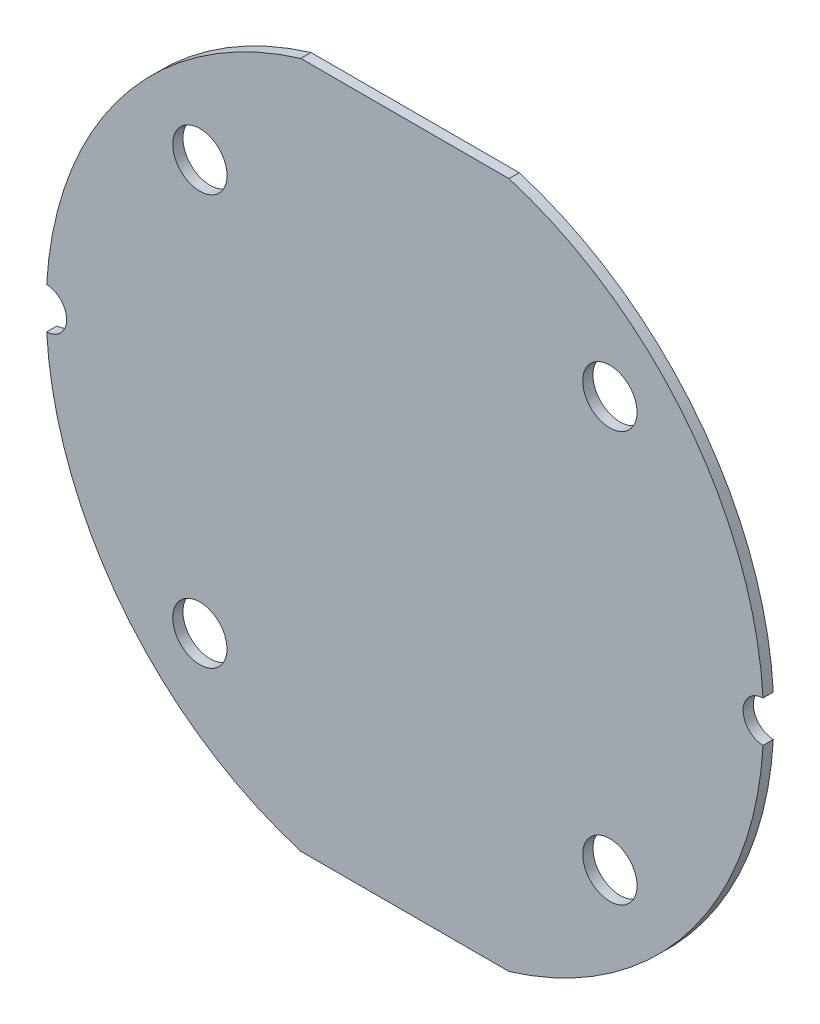
from build123d import *

# Parameters (mm, degrees)
SKETCH1_R           = 2.65
BOSS_EXTRUDE1_DEPTH = 1


with BuildPart() as part:
    # Sketch1 → Boss-Extrude1 (new body)
    with BuildSketch(Plane.XY):
        with BuildLine():
            Line((-10.16, 33.49290074), (10.16, 33.49290074))
            ThreePointArc((10.16, 33.49290074), (27.504846413, 21.644477906), (34.942810419, 2))
            ThreePointArc((34.942810419, 2), (32.999182505, 0), (34.942810419, -2))
            ThreePointArc((34.942810419, -2), (27.504846413, -21.644477906), (10.16, -33.49290074))
            Line((10.16, -33.49290074), (-10.16, -33.49290074))
            ThreePointArc((-10.16, -33.49290074), (-27.504846413, -21.644477906), (-34.942810419, -2))
            ThreePointArc((-34.942810419, -2), (-32.999182505, 0), (-34.942810419, 2))
            ThreePointArc((-34.942810419, 2), (-27.504846413, 21.644477906), (-10.16, 33.49290074))
        make_face()
        with Locations((-20, 20)):
            Circle(SKETCH1_R, mode=Mode.SUBTRACT)
        with Locations((-20, -20)):
            Circle(SKETCH1_R, mode=Mode.SUBTRACT)
        with Locations((20, -20)):
            Circle(SKETCH1_R, mode=Mode.SUBTRACT)
        with Locations((20, 20)):
            Circle(SKETCH1_R, mode=Mode.SUBTRACT)
    extrude(amount=BOSS_EXTRUDE1_DEPTH)


solid = part.part
